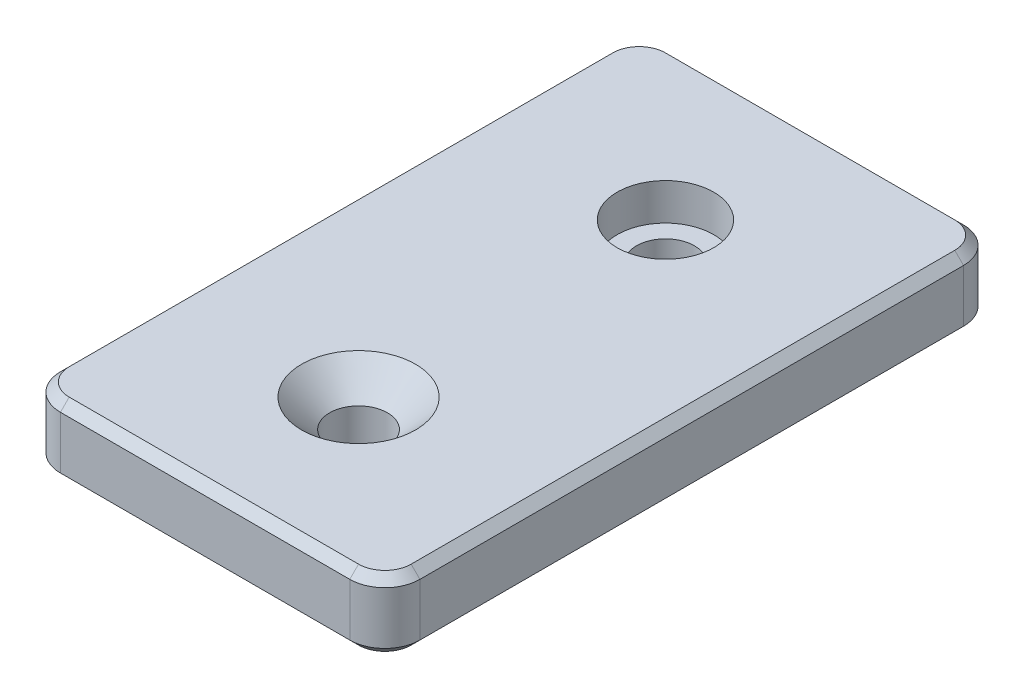
from build123d import *

# Parameters (mm, degrees)
SKETCH1_W           = 41
SKETCH1_H           = 70
BOSS_EXTRUDE1_DEPTH = 8
FILLET1_R           = 4
CHAMFER1_SIZE       = 1
SKETCH2_R           = 3.3
CUT_EXTRUDE1_DEPTH  = 8
CHAMFER2_SIZE       = 3.2
SKETCH3_R           = 5.5
CUT_EXTRUDE2_DEPTH  = 4.2
SKETCH4_R           = 5.1
CUT_EXTRUDE3_DEPTH  = 10
SKETCH5_R           = 10
CUT_EXTRUDE5_DEPTH  = 4
SKETCH6_R           = 10
BOSS_EXTRUDE2_DEPTH = 8


with BuildPart() as part:
    # Sketch1 → Boss-Extrude1 (new body)
    with BuildSketch(Plane(origin=(0, 0, 0), x_dir=(1, 0, 0), z_dir=(0, 1, 0))):
        Rectangle(SKETCH1_W, SKETCH1_H)
    extrude(amount=BOSS_EXTRUDE1_DEPTH)

    # Fillet1
    fillet1_edges = [part.edges().sort_by_distance(p)[0] for p in [
        (20.5, 4, 35),
        (-20.5, 4, 35),
        (-20.5, 4, -35),
        (20.5, 4, -35),
    ]]
    fillet(fillet1_edges, radius=FILLET1_R)

    # Chamfer1
    chamfer1_edges = [part.edges().sort_by_distance(p)[0] for p in [
        (-20.5, 0, 0),
        (-20.5, 8, 0),
        (20.5, 0, 0),
        (0, 0, 35),
        (0, 0, -35),
        (-19.328427125, 0, 33.828427125),
        (19.328427125, 0, 33.828427125),
        (19.328427125, 0, -33.828427125),
        (-19.328427125, 0, -33.828427125),
        (0, 8, -35),
        (20.5, 8, 0),
        (0, 8, 35),
        (-19.328427125, 8, 33.828427125),
        (19.328427125, 8, 33.828427125),
        (19.328427125, 8, -33.828427125),
        (-19.328427125, 8, -33.828427125),
    ]]
    chamfer(chamfer1_edges, length=CHAMFER1_SIZE)

    # Sketch2 → Cut-Extrude1 (cut)
    with BuildSketch(Plane(origin=(0, 8, 0), x_dir=(1, 0, 0), z_dir=(0, 1, 0))):
        with Locations((0, -17.5)):
            Circle(SKETCH2_R)
        with Locations((0, 17.5)):
            Circle(SKETCH2_R)
    extrude(amount=-CUT_EXTRUDE1_DEPTH, mode=Mode.SUBTRACT)

    # Chamfer2
    chamfer2_edges = [part.edges().sort_by_distance(p)[0] for p in [
        (-3.3, 8, 17.5),
    ]]
    chamfer(chamfer2_edges, length=CHAMFER2_SIZE)

    # Sketch3 → Cut-Extrude2 (cut)
    with BuildSketch(Plane(origin=(0, 8, 0), x_dir=(1, 0, 0), z_dir=(0, 1, 0))):
        with Locations((0, 17.5)):
            Circle(SKETCH3_R)
    extrude(amount=-CUT_EXTRUDE2_DEPTH, mode=Mode.SUBTRACT)

    # Sketch4 → Cut-Extrude3 (cut)
    with BuildSketch(Plane(origin=(0, 8, 0), x_dir=(1, 0, 0), z_dir=(0, 1, 0))):
        Circle(SKETCH4_R)
    extrude(amount=-CUT_EXTRUDE3_DEPTH, mode=Mode.SUBTRACT)

    # Sketch5 → Cut-Extrude5 (cut)
    with BuildSketch(Plane(origin=(0, 8, 0), x_dir=(1, 0, 0), z_dir=(0, 1, 0))):
        Circle(SKETCH5_R)
    extrude(amount=-CUT_EXTRUDE5_DEPTH, mode=Mode.SUBTRACT)

    # Sketch6 → Boss-Extrude2 (add)
    with BuildSketch(Plane(origin=(0, 8, 0), x_dir=(1, 0, 0), z_dir=(0, 1, 0))):
        Circle(SKETCH6_R)
    extrude(amount=-BOSS_EXTRUDE2_DEPTH)


solid = part.part
